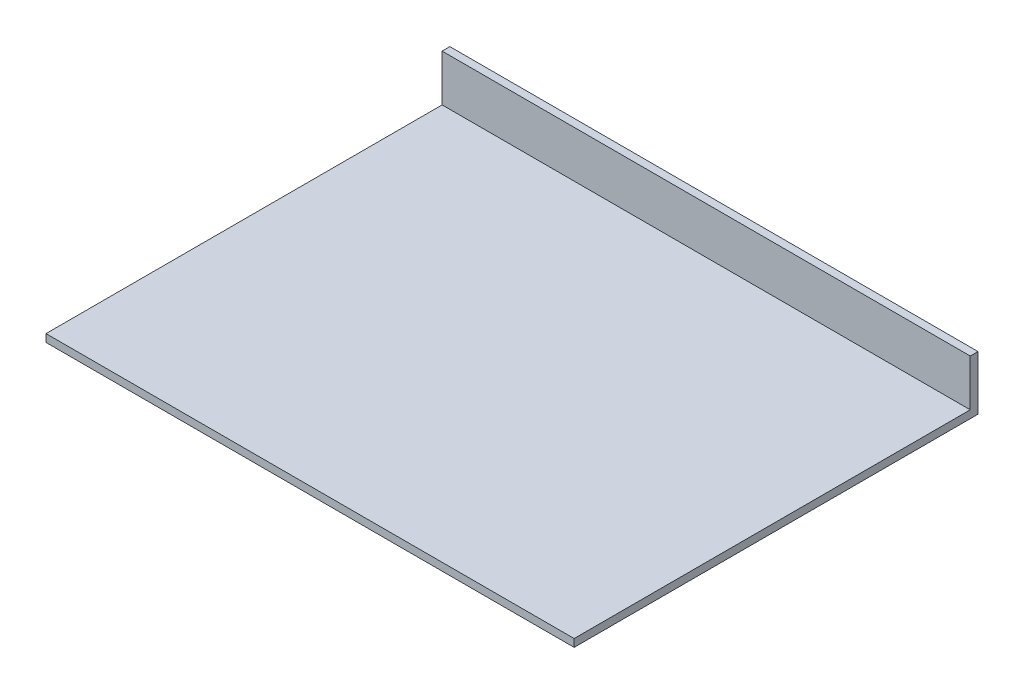
from build123d import *

# Parameters (mm, degrees)
SKETCH1_W           = 215.9
SKETCH1_H           = 165.1
BOSS_EXTRUDE3_DEPTH = 3.147705411
SKETCH3_W           = 215.9
SKETCH3_H           = 3.175
BOSS_EXTRUDE4_DEPTH = 19.05


with BuildPart() as part:
    # Sketch1 → Boss-Extrude3 (new body)
    with BuildSketch(Plane(origin=(0, 0, 0), x_dir=(1, 0, 0), z_dir=(0, 1, 0))):
        Rectangle(SKETCH1_W, SKETCH1_H)
    extrude(amount=BOSS_EXTRUDE3_DEPTH)

    # Sketch3 → Boss-Extrude4 (add)
    with BuildSketch(Plane(origin=(0, 3.147705411, 0), x_dir=(1, 0, 0), z_dir=(0, 1, 0))):
        with Locations((0, 80.9625)):
            Rectangle(SKETCH3_W, SKETCH3_H)
    extrude(amount=BOSS_EXTRUDE4_DEPTH)


solid = part.part
